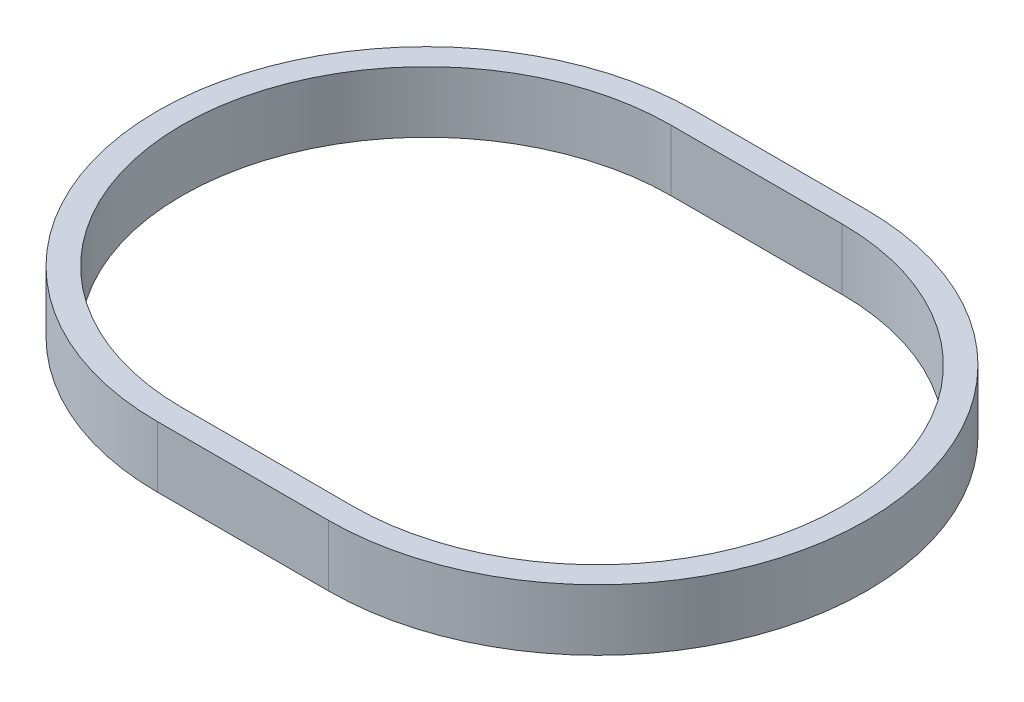
from build123d import *

# Parameters (mm, degrees)
BOSS_EXTRUDE1_DEPTH = 5


with BuildPart() as part:
    # Sketch1 → Boss-Extrude1 (new body)
    with BuildSketch(Plane(origin=(0, 0, 0), x_dir=(1, 0, 0), z_dir=(0, 1, 0))):
        with BuildLine():
            Line((0, 22), (14, 22))
            ThreePointArc((14, 22), (36, 0), (14, -22))
            Line((14, -22), (0, -22))
            ThreePointArc((0, -22), (-22, 0), (0, 22))
        make_face()
        with BuildLine():
            Line((0, 20), (14, 20))
            ThreePointArc((14, 20), (34, 0), (14, -20))
            Line((14, -20), (0, -20))
            ThreePointArc((0, -20), (-20, 0), (0, 20))
        make_face(mode=Mode.SUBTRACT)
    extrude(amount=BOSS_EXTRUDE1_DEPTH)


solid = part.part
